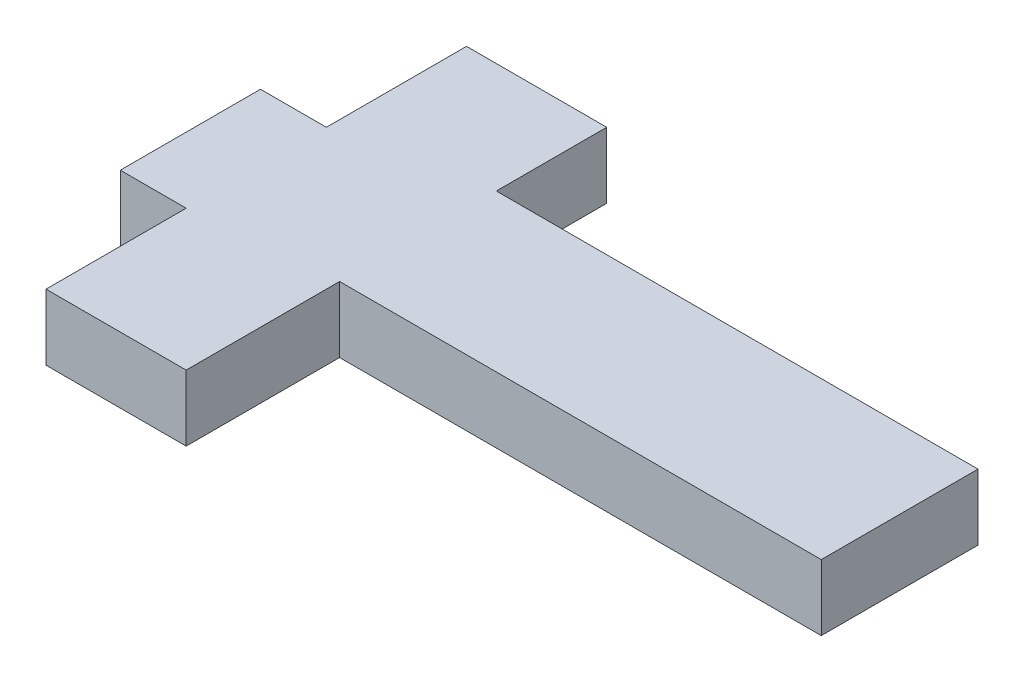
from build123d import *

# Parameters (mm, degrees)
BOSS_EXTRUDE1_DEPTH = 5.969
SKETCH2_W           = 37.669
SKETCH2_H           = 14.2
BOSS_EXTRUDE2_DEPTH = 5.969


with BuildPart() as part:
    # Sketch1 → Boss-Extrude1 (new body)
    with BuildSketch(Plane(origin=(0, 0, 0), x_dir=(1, 0, 0), z_dir=(0, 1, 0))):
        Polygon((0, 0), (12.7, 0), (12.7, 13.9), (18.669, 13.9), (18.669, 28.1), (12.7, 28.1), (12.7, 38.1), (0, 38.1), (0, 25.4), (-5.969, 25.4), (-5.969, 12.7), (0, 12.7), align=None)
    extrude(amount=BOSS_EXTRUDE1_DEPTH)

    # Sketch2 → Boss-Extrude2 (add)
    with BuildSketch(Plane.XZ):
        with Locations((37.5035, -21)):
            Rectangle(SKETCH2_W, SKETCH2_H)
    extrude(amount=-BOSS_EXTRUDE2_DEPTH)


solid = part.part
